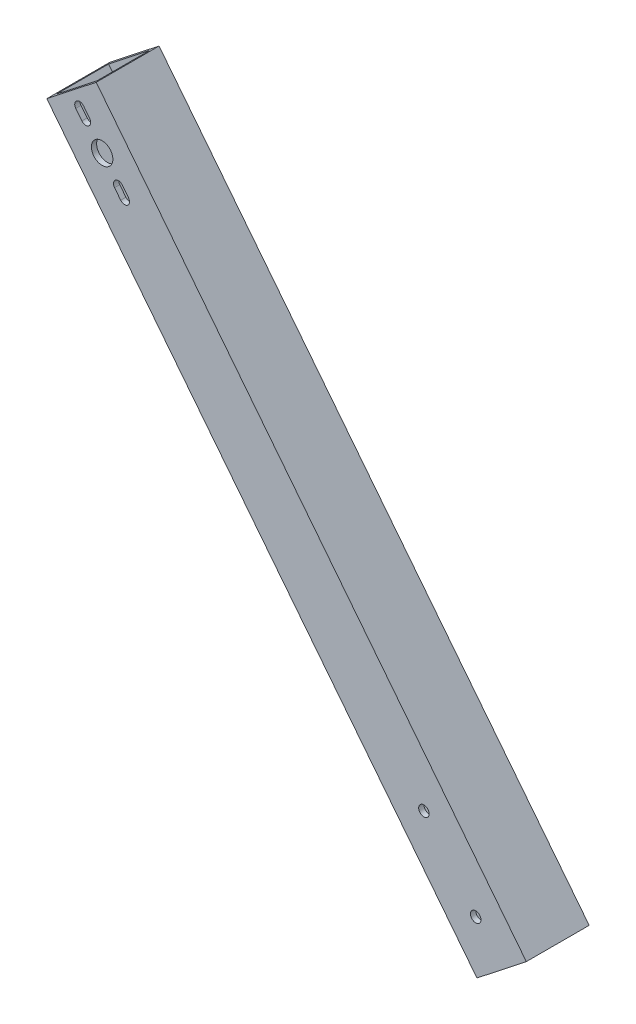
from build123d import *

# Parameters (mm, degrees)
BOSS_EXTRUDE1_DEPTH = 19.05
SHELL1_T            = -1.5875
SKETCH2_W           = 15.875
SKETCH2_H           = 15.875
CUT_EXTRUDE1_DEPTH  = 221.078395706
SKETCH3_R           = 3.25
CUT_EXTRUDE2_DEPTH  = 2.54
SKETCH7_R           = 1.5875
CUT_EXTRUDE3_DEPTH  = 20.05
CUT_EXTRUDE4_DEPTH  = 19.05


with BuildPart() as part:
    # Sketch1 → Boss-Extrude1 (new body)
    with BuildSketch(Plane.XY):
        Polygon((-220.570309856, 200.660746496), (-205.600965293, 212.442988361), (-75.21082199, 46.782241865), (-90.180166553, 35), align=None)
    extrude(amount=BOSS_EXTRUDE1_DEPTH)

    # Shell1
    shell1_openings = [part.faces().sort_by_distance(p)[0] for p in [
        (-82.695494272, 40.891120932, 9.525),
    ]]
    offset(amount=SHELL1_T, openings=shell1_openings, kind=Kind.INTERSECTION)

    # Sketch2 → Cut-Extrude1 (cut, through all)
    with BuildSketch(Plane(origin=(-181.896970564, 231.100197958, 0), x_dir=(0.785792366, 0.618490387, 0), z_dir=(-0.618490387, 0.785792366, 0))):
        with Locations((-39.690722867, -9.525)):
            Rectangle(SKETCH2_W, SKETCH2_H)
    extrude(amount=-CUT_EXTRUDE1_DEPTH, mode=Mode.SUBTRACT)

    # Sketch3 → Cut-Extrude2 (cut)
    with BuildSketch(Plane.XY.offset(19.05)):
        with Locations((-203.807891879, 194.764486582)):
            Circle(SKETCH3_R)
    extrude(amount=-CUT_EXTRUDE2_DEPTH, mode=Mode.SUBTRACT)

    # Sketch7 → Cut-Extrude3 (cut, through all)
    with BuildSketch(Plane.XY.offset(19.05)):
        with Locations((-106.259978001, 70.829810058)):
            Circle(SKETCH7_R)
        with Locations((-90.550322182, 50.870683974)):
            Circle(SKETCH7_R)
    extrude(amount=-CUT_EXTRUDE3_DEPTH, mode=Mode.SUBTRACT)

    # Sketch9 → Cut-Extrude4 (cut)
    with BuildSketch(Plane.XY.offset(19.05)):
        with BuildLine():
            Line((-197.681280238, 189.405883238), (-195.825809078, 187.048506142))
            ThreePointArc((-195.825809078, 187.048506142), (-196.076762046, 184.942082013), (-198.183186175, 185.193034982))
            Line((-198.183186175, 185.193034982), (-200.038657334, 187.550412078))
            ThreePointArc((-200.038657334, 187.550412078), (-199.787704366, 189.656836206), (-197.681280238, 189.405883238))
        make_face()
        with BuildLine():
            Line((-209.432597583, 204.335938183), (-207.577126423, 201.978561086))
            ThreePointArc((-207.577126423, 201.978561086), (-207.828079392, 199.872136958), (-209.93450352, 200.123089926))
            Line((-209.93450352, 200.123089926), (-211.78997468, 202.480467023))
            ThreePointArc((-211.78997468, 202.480467023), (-211.539021711, 204.586891151), (-209.432597583, 204.335938183))
        make_face()
    extrude(amount=-CUT_EXTRUDE4_DEPTH, mode=Mode.SUBTRACT)


solid = part.part
